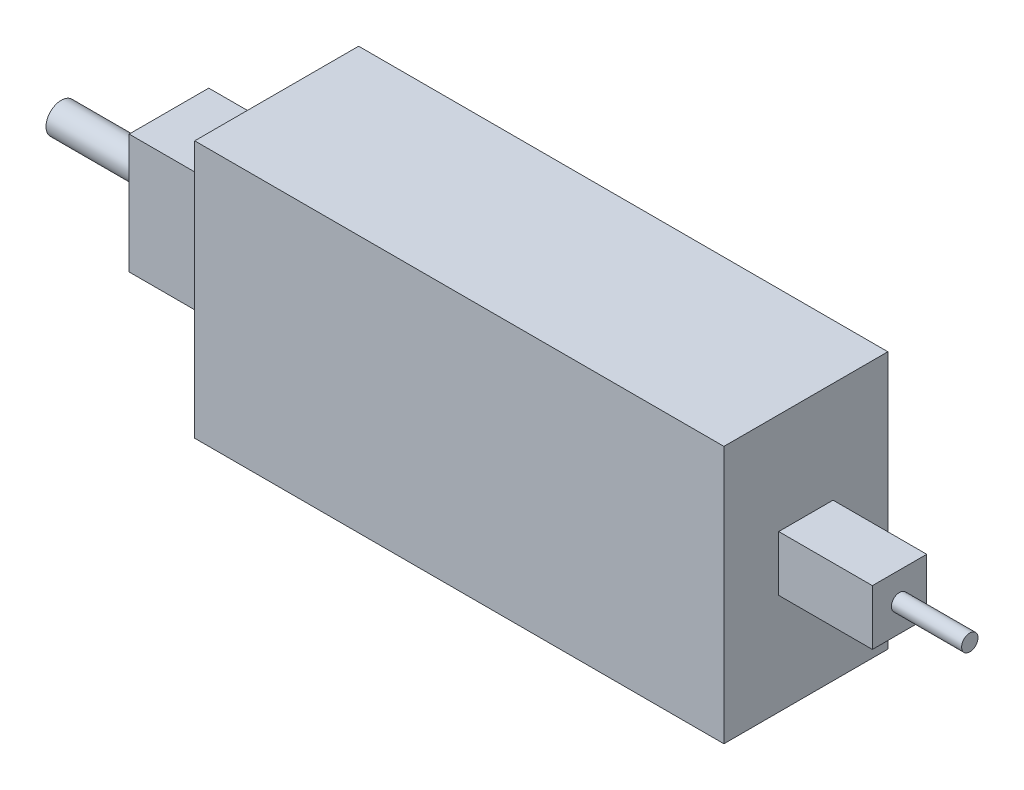
from build123d import *

# Parameters (mm, degrees)
SKETCH1_W           = 113
SKETCH1_H           = 55
BOSS_EXTRUDE2_DEPTH = 35
SKETCH3_W           = 11.6
SKETCH3_H           = 11.8
BOSS_EXTRUDE3_DEPTH = 20
SKETCH4_R           = 1.75
BOSS_EXTRUDE4_DEPTH = 15
SKETCH5_W           = 17
SKETCH5_H           = 25.5
BOSS_EXTRUDE5_DEPTH = 23
SKETCH6_R           = 3.25
BOSS_EXTRUDE6_DEPTH = 23


with BuildPart() as part:
    # Sketch1 → Boss-Extrude2 (new body)
    with BuildSketch(Plane.XY):
        with Locations((56.5, 27.5)):
            Rectangle(SKETCH1_W, SKETCH1_H)
    extrude(amount=BOSS_EXTRUDE2_DEPTH)

    # Sketch3 → Boss-Extrude3 (add)
    with BuildSketch(Plane(origin=(113, 0, 0), x_dir=(0, 0, -1), z_dir=(1, 0, 0))):
        with Locations((-17.5, 27.5)):
            Rectangle(SKETCH3_W, SKETCH3_H)
    extrude(amount=BOSS_EXTRUDE3_DEPTH)

    # Sketch4 → Boss-Extrude4 (add)
    with BuildSketch(Plane(origin=(133, 0, 0), x_dir=(0, 0, -1), z_dir=(1, 0, 0))):
        with Locations((-17.5, 27.5)):
            Circle(SKETCH4_R)
    extrude(amount=BOSS_EXTRUDE4_DEPTH)

    # Sketch5 → Boss-Extrude5 (add)
    with BuildSketch(Plane.ZY):
        with Locations((17.5, 27.5)):
            Rectangle(SKETCH5_W, SKETCH5_H)
    extrude(amount=BOSS_EXTRUDE5_DEPTH)

    # Sketch6 → Boss-Extrude6 (add)
    with BuildSketch(Plane.ZY.offset(23)):
        with Locations((17.5, 27.5)):
            Circle(SKETCH6_R)
    extrude(amount=BOSS_EXTRUDE6_DEPTH)


solid = part.part
